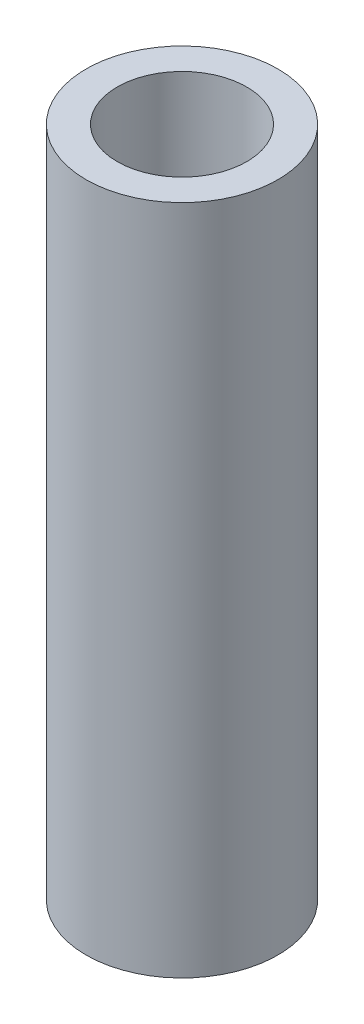
from build123d import *

# Parameters (mm, degrees)
SKETCH1_R           = 2.54
SKETCH1_R_2         = 1.7145
BOSS_EXTRUDE1_DEPTH = 17.78


with BuildPart() as part:
    # Sketch1 → Boss-Extrude1 (new body)
    with BuildSketch(Plane(origin=(0, 0, 0), x_dir=(1, 0, 0), z_dir=(0, 1, 0))):
        Circle(SKETCH1_R)
        Circle(SKETCH1_R_2, mode=Mode.SUBTRACT)
    extrude(amount=BOSS_EXTRUDE1_DEPTH)


solid = part.part
